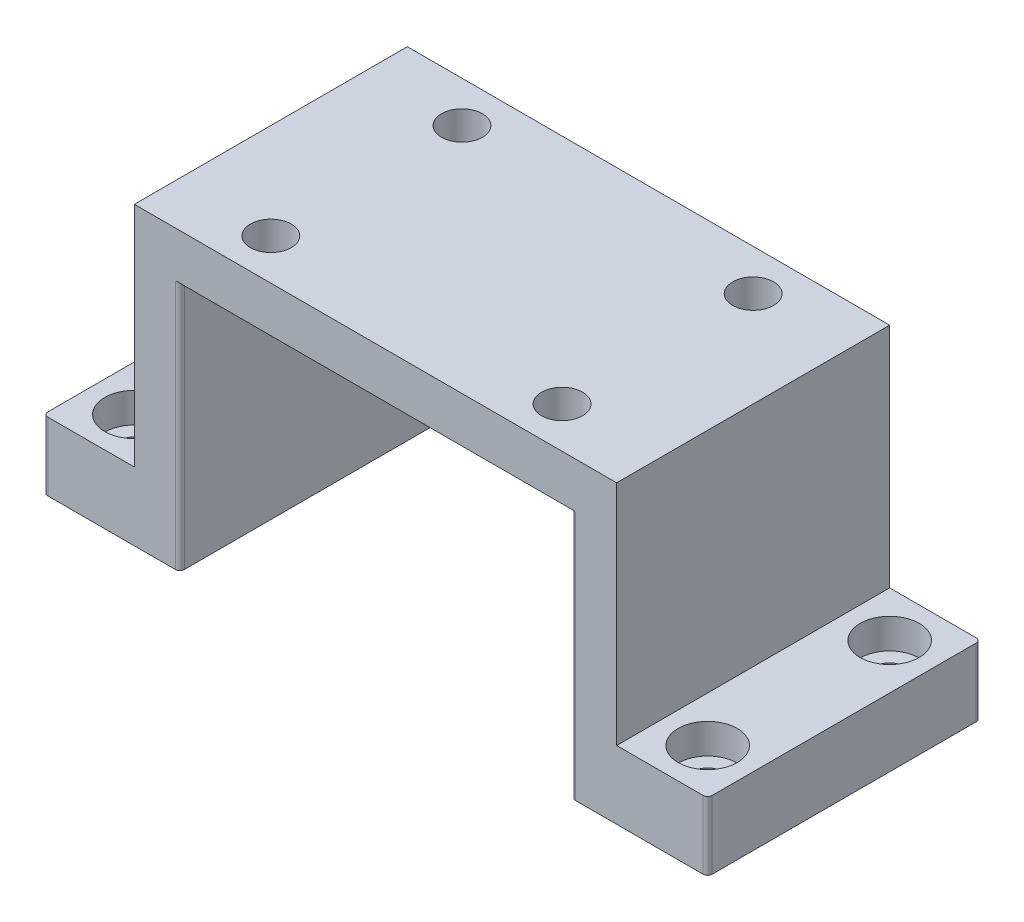
from build123d import *

# Parameters (mm, degrees)
SKETCH1_W           = 106
SKETCH1_H           = 60
BOSS_EXTRUDE1_DEPTH = 10
SKETCH2_W           = 10
SKETCH2_H           = 60
BOSS_EXTRUDE2_DEPTH = 55
SKETCH3_W           = 60
SKETCH3_H           = 15
BOSS_EXTRUDE3_DEPTH = 20
SKETCH4_W           = 60
SKETCH4_H           = 15
BOSS_EXTRUDE4_DEPTH = 20
SKETCH5_R           = 4.5
CUT_EXTRUDE1_DEPTH  = 66
SKETCH6_R           = 6.5
CUT_EXTRUDE2_DEPTH  = 6.6
SKETCH7_R           = 3.3
CUT_EXTRUDE3_DEPTH  = 9.4
FILLET1_R           = 1


with BuildPart() as part:
    # Sketch1 → Boss-Extrude1 (new body)
    with BuildSketch(Plane(origin=(0, 0, 0), x_dir=(1, 0, 0), z_dir=(0, 1, 0))):
        Rectangle(SKETCH1_W, SKETCH1_H)
    extrude(amount=BOSS_EXTRUDE1_DEPTH)

    # Sketch2 → Boss-Extrude2 (add)
    with BuildSketch(Plane.XZ):
        with Locations((-48, 0)):
            Rectangle(SKETCH2_W, SKETCH2_H)
        with Locations((48, 0)):
            Rectangle(SKETCH2_W, SKETCH2_H)
    extrude(amount=BOSS_EXTRUDE2_DEPTH)

    # Sketch3 → Boss-Extrude3 (add)
    with BuildSketch(Plane(origin=(53, 0, 0), x_dir=(0, 0, -1), z_dir=(1, 0, 0))):
        with Locations((0, -47.5)):
            Rectangle(SKETCH3_W, SKETCH3_H)
    extrude(amount=BOSS_EXTRUDE3_DEPTH)

    # Sketch4 → Boss-Extrude4 (add)
    with BuildSketch(Plane.ZY.offset(53)):
        with Locations((0, -47.5)):
            Rectangle(SKETCH4_W, SKETCH4_H)
    extrude(amount=BOSS_EXTRUDE4_DEPTH)

    # Sketch5 → Cut-Extrude1 (cut, through all)
    with BuildSketch(Plane(origin=(0, 10, 0), x_dir=(1, 0, 0), z_dir=(0, 1, 0))):
        with Locations((-32, 21)):
            Circle(SKETCH5_R)
        with Locations((32, 21)):
            Circle(SKETCH5_R)
        with Locations((32, -21)):
            Circle(SKETCH5_R)
        with Locations((-32, -21)):
            Circle(SKETCH5_R)
    extrude(amount=-CUT_EXTRUDE1_DEPTH, mode=Mode.SUBTRACT)

    # Sketch6 → Cut-Extrude2 (cut)
    with BuildSketch(Plane(origin=(0, -40, 0), x_dir=(1, 0, 0), z_dir=(0, 1, 0))):
        with Locations((63, 20)):
            Circle(SKETCH6_R)
        with Locations((63, -20)):
            Circle(SKETCH6_R)
        with Locations((-63, 20)):
            Circle(SKETCH6_R)
        with Locations((-63, -20)):
            Circle(SKETCH6_R)
    extrude(amount=-CUT_EXTRUDE2_DEPTH, mode=Mode.SUBTRACT)

    # Sketch7 → Cut-Extrude3 (cut, through all)
    with BuildSketch(Plane(origin=(0, -46.6, 0), x_dir=(1, 0, 0), z_dir=(0, 1, 0))):
        with Locations((-63, 20)):
            Circle(SKETCH7_R)
        with Locations((-63, -20)):
            Circle(SKETCH7_R)
        with Locations((63, -20)):
            Circle(SKETCH7_R)
        with Locations((63, 20)):
            Circle(SKETCH7_R)
    extrude(amount=-CUT_EXTRUDE3_DEPTH, mode=Mode.SUBTRACT)

    # Fillet1
    fillet1_edges = [part.edges().sort_by_distance(p)[0] for p in [
        (-43, -27.5, -30),
        (-43, -27.5, 30),
        (43, -27.5, 30),
        (43, -27.5, -30),
        (73, -47.5, 30),
        (73, -47.5, -30),
        (-73, -47.5, -30),
        (-73, -47.5, 30),
    ]]
    fillet(fillet1_edges, radius=FILLET1_R)


solid = part.part
